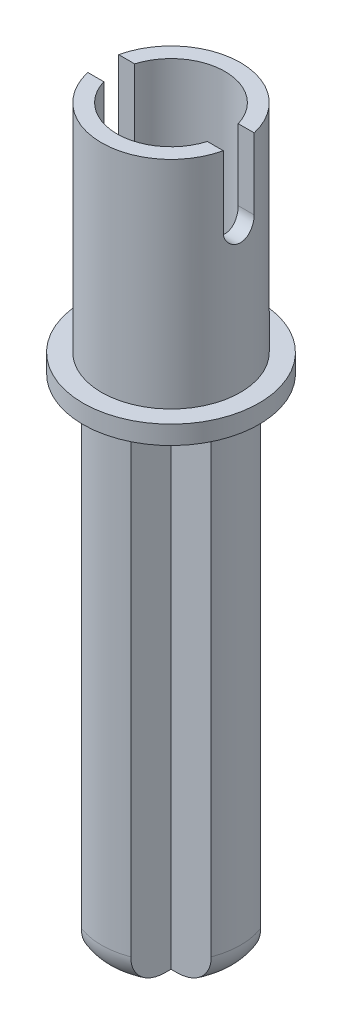
from build123d import *

# Parameters (mm, degrees)
BOSS_EXTRUDE1_DEPTH = 16.5
FILLET1_R           = 1
FILLET2_R           = 1
FILLET3_R           = 1
FILLET4_R           = 1
SKETCH3_R           = 2.85
BOSS_EXTRUDE2_DEPTH = 0.6
SKETCH4_R           = 2.25
BOSS_EXTRUDE3_DEPTH = 7
CUT_EXTRUDE2_DEPTH  = 27.935014386
SKETCH8_R           = 1.75
CUT_EXTRUDE3_DEPTH  = 7


with BuildPart() as part:
    # Sketch1 → Boss-Extrude1 (new body)
    with BuildSketch(Plane(origin=(0, 0, 0), x_dir=(1, 0, 0), z_dir=(0, 1, 0))):
        with BuildLine():
            Line((-0.8, -0.8), (-0.8, -2.102974084))
            ThreePointArc((-0.8, -2.102974084), (0, -2.25), (0.8, -2.102974084))
            Line((0.8, -2.102974084), (0.8, -0.8))
            Line((0.8, -0.8), (2.102974084, -0.8))
            ThreePointArc((2.102974084, -0.8), (2.25, 0), (2.102974084, 0.8))
            Line((2.102974084, 0.8), (0.8, 0.8))
            Line((0.8, 0.8), (0.8, 2.102974084))
            ThreePointArc((0.8, 2.102974084), (0, 2.25), (-0.8, 2.102974084))
            Line((-0.8, 2.102974084), (-0.8, 0.8))
            Line((-0.8, 0.8), (-2.102974084, 0.8))
            ThreePointArc((-2.102974084, 0.8), (-2.25, 0), (-2.102974084, -0.8))
            Line((-2.102974084, -0.8), (-0.8, -0.8))
        make_face()
    extrude(amount=BOSS_EXTRUDE1_DEPTH)

    # Fillet1
    fillet1_edges = [part.edges().sort_by_distance(p)[0] for p in [
        (-2.25, 0, 0),
    ]]
    fillet(fillet1_edges, radius=FILLET1_R)

    # Fillet2
    fillet2_edges = [part.edges().sort_by_distance(p)[0] for p in [
        (0, 0, 2.25),
    ]]
    fillet(fillet2_edges, radius=FILLET2_R)

    # Fillet3
    fillet3_edges = [part.edges().sort_by_distance(p)[0] for p in [
        (2.25, 0, 0),
    ]]
    fillet(fillet3_edges, radius=FILLET3_R)

    # Fillet4
    fillet4_edges = [part.edges().sort_by_distance(p)[0] for p in [
        (0, 0, -2.25),
    ]]
    fillet(fillet4_edges, radius=FILLET4_R)

    # Sketch3 → Boss-Extrude2 (add)
    with BuildSketch(Plane(origin=(0, 16.5, 0), x_dir=(1, 0, 0), z_dir=(0, 1, 0))):
        with Locations(Location((0, 0, 0), (0, 0, 270))):
            Circle(SKETCH3_R)
    extrude(amount=-BOSS_EXTRUDE2_DEPTH)

    # Sketch4 → Boss-Extrude3 (add)
    with BuildSketch(Plane(origin=(0, 16.5, 0), x_dir=(1, 0, 0), z_dir=(0, 1, 0))):
        with Locations(Location((0, 0, 0), (0, 0, 270))):
            Circle(SKETCH4_R)
    extrude(amount=BOSS_EXTRUDE3_DEPTH)

    # Sketch5 → Cut-Extrude2 (cut, through all)
    with BuildSketch(Plane(origin=(10, 0, 0), x_dir=(0, 0, -1), z_dir=(1, 0, 0))):
        with BuildLine():
            Line((-0.5, 21.2), (-0.5, 23.5))
            ThreePointArc((-0.5, 23.5), (0, 24), (0.5, 23.5))
            Line((0.5, 23.5), (0.5, 21.2))
            ThreePointArc((0.5, 21.2), (0, 20.7), (-0.5, 21.2))
        make_face()
    extrude(amount=-CUT_EXTRUDE2_DEPTH, mode=Mode.SUBTRACT)

    # Sketch8 → Cut-Extrude3 (cut)
    with BuildSketch(Plane(origin=(0, 23.5, 0), x_dir=(1, 0, 0), z_dir=(0, 1, 0))):
        with Locations(Location((0, 0, 0), (0, 0, 270))):
            Circle(SKETCH8_R)
    extrude(amount=-CUT_EXTRUDE3_DEPTH, mode=Mode.SUBTRACT)


solid = part.part
